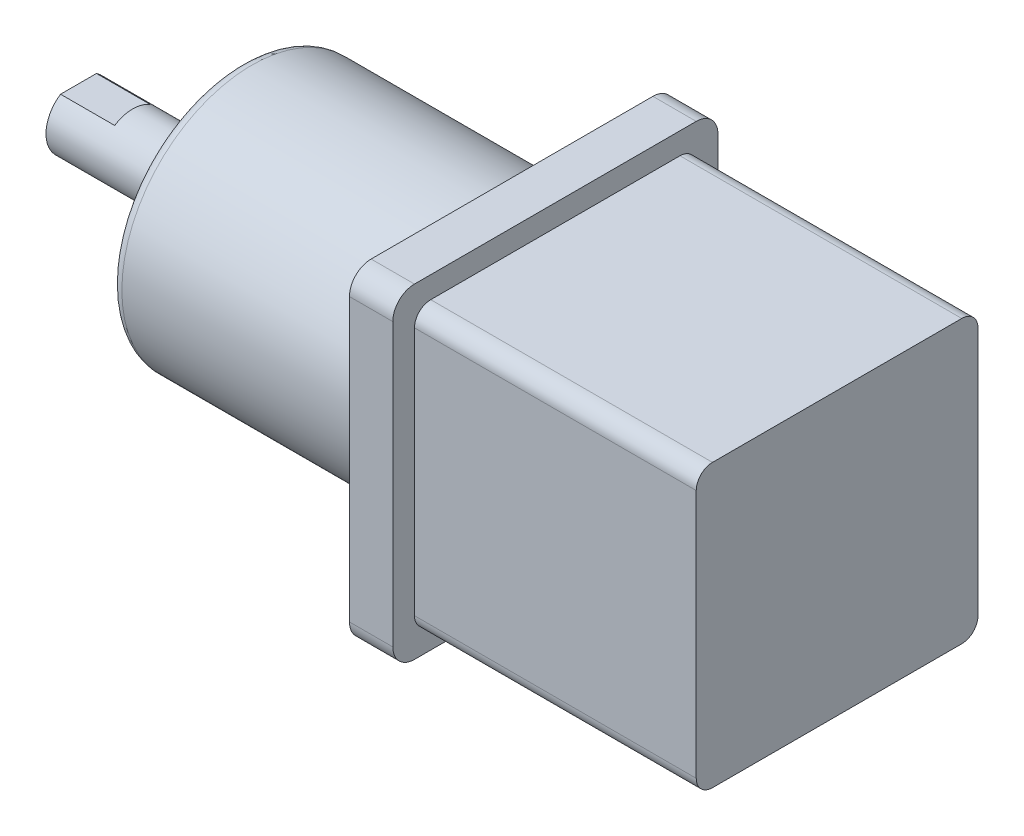
from build123d import *

# Parameters (mm, degrees)
SKETCH_1_W          = 30
SKETCH_1_H          = 30
EXTRUDE_1_DEPTH     = 30
SKETCH_2_R          = 12
EXTRUDE_2_DEPTH     = 25
SKETCH_3_R          = 13
SKETCH_3_R_2        = 12
CUT_EXTRUDE_1_DEPTH = 1
FILLET_1_R          = 2
FILLET_2_R          = 1
SKETCH_5_W          = 30
SKETCH_5_H          = 30
SKETCH_5_W_2        = 26
SKETCH_5_H_2        = 26
CUT_EXTRUDE_2_DEPTH = 26
FILLET_3_R          = 1.5
SKETCH_4_R          = 3
EXTRUDE_3_DEPTH     = 15
SKETCH_6_W          = 3.31662479
SKETCH_6_H          = 0.5
CUT_EXTRUDE_3_DEPTH = 5


with BuildPart() as part:
    # 草图1 → 凸台-拉伸1 (new body)
    with BuildSketch(Plane(origin=(0, 0, 0), x_dir=(0, 0, -1), z_dir=(1, 0, 0))):
        Rectangle(SKETCH_1_W, SKETCH_1_H)
    extrude(amount=EXTRUDE_1_DEPTH)

    # 草图2 → 凸台-拉伸2 (add)
    with BuildSketch(Plane.ZY):
        Circle(SKETCH_2_R)
    extrude(amount=EXTRUDE_2_DEPTH)

    # 草图3 → 切除-拉伸1 (cut)
    with BuildSketch(Plane.ZY):
        Circle(SKETCH_3_R)
        Circle(SKETCH_3_R_2, mode=Mode.SUBTRACT)
    extrude(amount=-CUT_EXTRUDE_1_DEPTH, mode=Mode.SUBTRACT)

    # 圆角1
    fillet_1_edges = [part.edges().sort_by_distance(p)[0] for p in [
        (15, 15, 15),
        (15, 15, -15),
        (15, -15, -15),
        (15, -15, 15),
    ]]
    fillet(fillet_1_edges, radius=FILLET_1_R)

    # 圆角2
    fillet_2_edges = [part.edges().sort_by_distance(p)[0] for p in [
        (-25, 0, -12),
    ]]
    fillet(fillet_2_edges, radius=FILLET_2_R)

    # 草图5 → 切除-拉伸2 (cut)
    with BuildSketch(Plane(origin=(30, 0, 0), x_dir=(0, 0, -1), z_dir=(1, 0, 0))):
        Rectangle(SKETCH_5_W, SKETCH_5_H)
        Rectangle(SKETCH_5_W_2, SKETCH_5_H_2, mode=Mode.SUBTRACT)
    extrude(amount=-CUT_EXTRUDE_2_DEPTH, mode=Mode.SUBTRACT)

    # 圆角3
    fillet_3_edges = [part.edges().sort_by_distance(p)[0] for p in [
        (17, 13, 13),
        (17, 13, -13),
        (17, -13, -13),
        (17, -13, 13),
    ]]
    fillet(fillet_3_edges, radius=FILLET_3_R)

    # 草图4 → 凸台-拉伸3 (add)
    with BuildSketch(Plane.ZY.offset(25)):
        Circle(SKETCH_4_R)
    extrude(amount=EXTRUDE_3_DEPTH)

    # 草图6 → 切除-拉伸3 (cut)
    with BuildSketch(Plane.ZY.offset(40)):
        with Locations((0, 2.75)):
            Rectangle(SKETCH_6_W, SKETCH_6_H)
    extrude(amount=-CUT_EXTRUDE_3_DEPTH, mode=Mode.SUBTRACT)


solid = part.part
